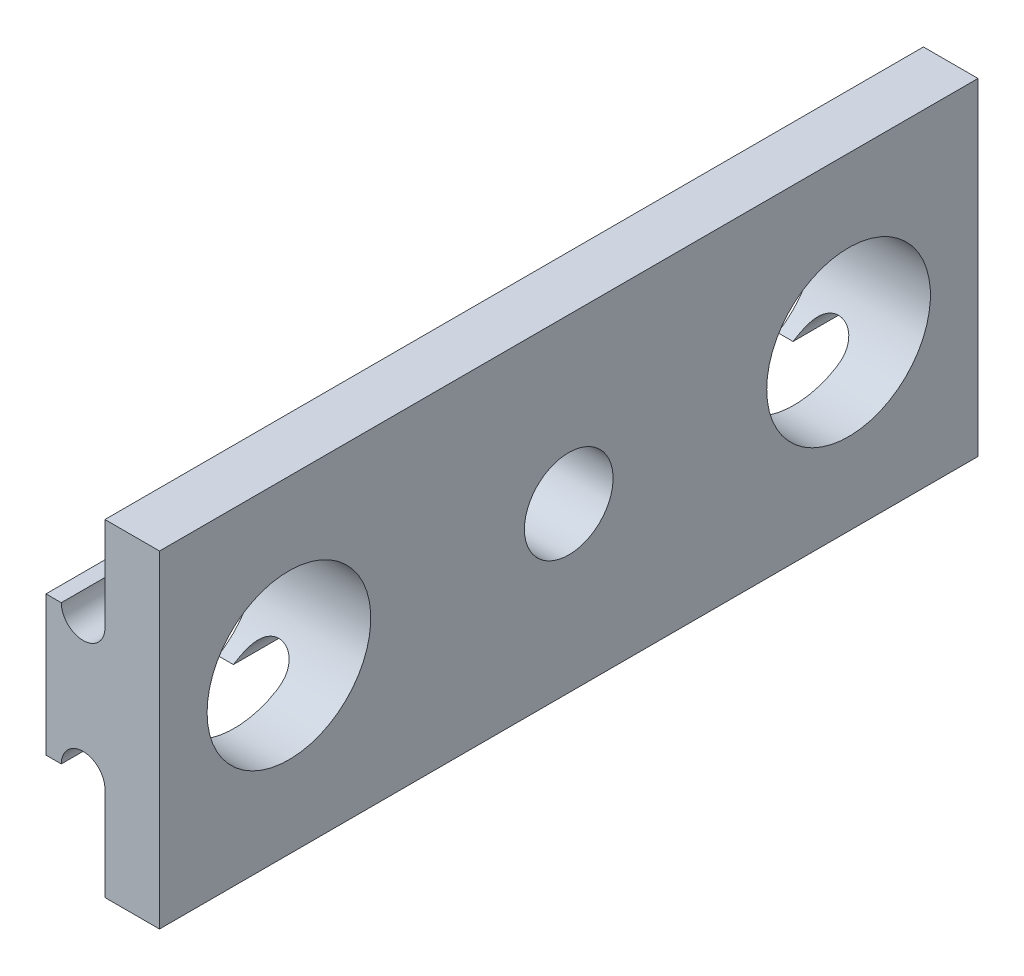
from build123d import *

# Parameters (mm, degrees)
BOSS_EXTRUDE1_DEPTH = 23.8125
SKETCH2_R           = 2.5796875
CUT_EXTRUDE1_DEPTH  = 7.604
SKETCH3_R           = 4.7625
CUT_EXTRUDE2_DEPTH  = 7.604


with BuildPart() as part:
    # Sketch1 → Boss-Extrude1 (new body, symmetric)
    with BuildSketch(Plane.XY):
        with BuildLine():
            Line((0, -9.525), (0, 9.525))
            Line((0, 9.525), (-3.175, 9.525))
            Line((-3.175, 9.525), (-3.175, 4.064))
            ThreePointArc((-3.175, 4.064), (-4.445, 2.794), (-5.715, 4.064))
            Line((-5.715, 4.064), (-6.604, 4.064))
            Line((-6.604, 4.064), (-6.604, -4.064))
            Line((-6.604, -4.064), (-5.715, -4.064))
            ThreePointArc((-5.715, -4.064), (-4.445, -2.794), (-3.175, -4.064))
            Line((-3.175, -4.064), (-3.175, -9.525))
            Line((-3.175, -9.525), (0, -9.525))
        make_face()
    extrude(amount=BOSS_EXTRUDE1_DEPTH, both=True)

    # Sketch2 → Cut-Extrude1 (cut, through all)
    with BuildSketch(Plane.ZY.offset(6.604)):
        with Locations((16.2814, 0)):
            Circle(SKETCH2_R)
        with Locations((-16.2814, 0)):
            Circle(SKETCH2_R)
        Circle(SKETCH2_R)
    extrude(amount=-CUT_EXTRUDE1_DEPTH, mode=Mode.SUBTRACT)

    # Sketch3 → Cut-Extrude2 (cut, through all)
    with BuildSketch(Plane.ZY.offset(6.604)):
        with Locations((-16.2814, 0)):
            Circle(SKETCH3_R)
        with Locations((16.2814, 0)):
            Circle(SKETCH3_R)
    extrude(amount=-CUT_EXTRUDE2_DEPTH, mode=Mode.SUBTRACT)


solid = part.part
